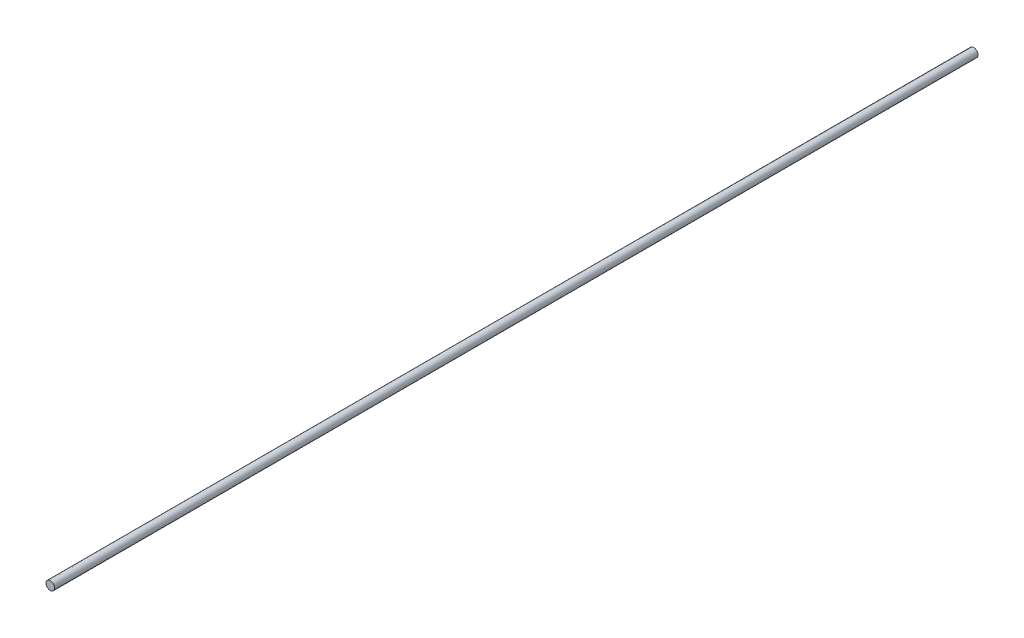
from build123d import *

# Parameters (mm, degrees)
SKETCH1_R           = 7.5
BOSS_EXTRUDE1_DEPTH = 1615
SKETCH2_R           = 4
CUT_EXTRUDE1_DEPTH  = 40


with BuildPart() as part:
    # Sketch1 → Boss-Extrude1 (new body)
    with BuildSketch(Plane.XY):
        Circle(SKETCH1_R)
    extrude(amount=BOSS_EXTRUDE1_DEPTH)

    # Sketch2 → Cut-Extrude1 (cut)
    with BuildSketch(Plane(origin=(0, 0, 0), x_dir=(-1, 0, 0), z_dir=(0, 0, -1))):
        Circle(SKETCH2_R)
    extrude(amount=-CUT_EXTRUDE1_DEPTH, mode=Mode.SUBTRACT)


solid = part.part
